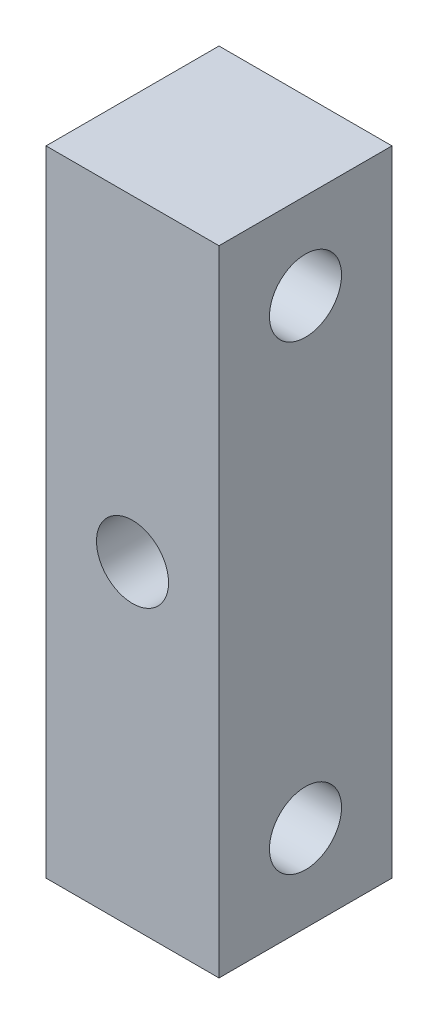
from build123d import *

# Parameters (mm, degrees)
SKETCH_1_W          = 6
SKETCH_1_H          = 22
SKETCH_1_R          = 1.25
EXTRUDE_1_DEPTH     = 6
SKETCH_2_R          = 1.25
CUT_EXTRUDE_1_DEPTH = 7


with BuildPart() as part:
    # 草图1 → 凸台-拉伸1 (new body)
    with BuildSketch(Plane(origin=(0, 0, 0), x_dir=(0, 0, -1), z_dir=(1, 0, 0))):
        Rectangle(SKETCH_1_W, SKETCH_1_H)
        with Locations((0, 8)):
            Circle(SKETCH_1_R, mode=Mode.SUBTRACT)
        with Locations((0, -8)):
            Circle(SKETCH_1_R, mode=Mode.SUBTRACT)
    extrude(amount=EXTRUDE_1_DEPTH)

    # 草图2 → 切除-拉伸1 (cut, through all)
    with BuildSketch(Plane.XY.offset(3)):
        with Locations((3, 0)):
            Circle(SKETCH_2_R)
    extrude(amount=-CUT_EXTRUDE_1_DEPTH, mode=Mode.SUBTRACT)


solid = part.part
